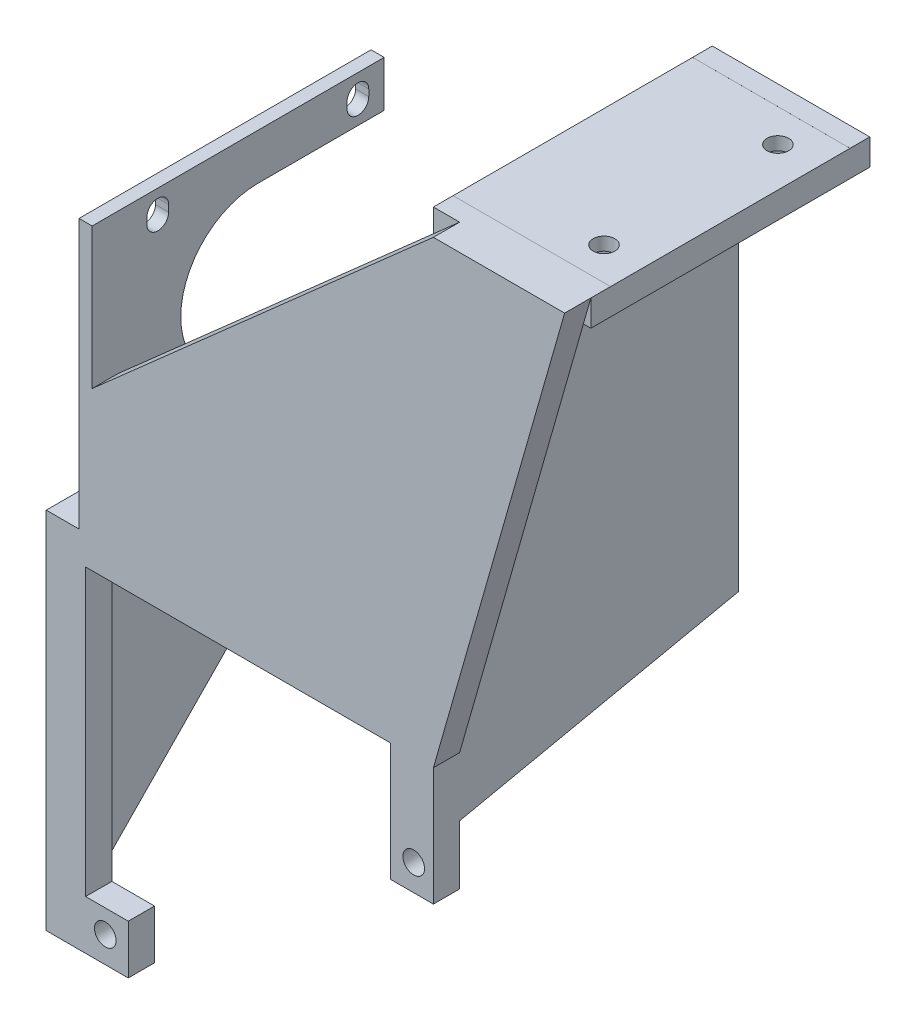
from build123d import *

# Parameters (mm, degrees)
SKETCH1_W                 = 13
SKETCH1_H                 = 16
BOSS_EXTRUDE1_DEPTH       = 4
SKETCH2_R                 = 1.65
CUT_EXTRUDE1_DEPTH        = 10
SKETCH3_W                 = 4
SKETCH3_H                 = 13
BOSS_EXTRUDE2_DEPTH       = 4
SKETCH4_W                 = 13
SKETCH4_H                 = 4
BOSS_EXTRUDE3_DEPTH       = 60
SKETCH6_W                 = 4
SKETCH6_H                 = 21
SKETCH6_H_2               = 13
BOSS_EXTRUDE4_DEPTH       = 28
SKETCH12_W                = 4
SKETCH12_H                = 28
BOSS_EXTRUDE8_DEPTH       = 1.65
SKETCH13_W                = 4
SKETCH13_H                = 28
BOSS_EXTRUDE9_DEPTH       = 1.65
SKETCH14_W                = 4
SKETCH14_H                = 35.878399396
CUT_EXTRUDE5_DEPTH        = 24
SKETCH15_R                = 1.65
CUT_EXTRUDE6_DEPTH        = 24
SKETCH16_W                = 4
SKETCH16_H                = 11.121600604
SKETCH16_H_2              = 11.3
BOSS_EXTRUDE10_DEPTH      = 29.15
SKETCH17_R                = 1.65
CUT_EXTRUDE8_DEPTH        = 29.15
SKETCH18_W                = 22.65
SKETCH18_H                = 4
SKETCH18_W_2              = 13
BOSS_EXTRUDE11_DEPTH      = 4
SKETCH19_W                = 4
SKETCH19_H                = 20
BOSS_EXTRUDE12_DEPTH      = 40
SKETCH20_R                = 1.65
CUT_EXTRUDE9_DEPTH        = 40
SKETCH21_W                = 4
SKETCH21_H                = 30.5
BOSS_EXTRUDE13_DEPTH      = 38.5
SKETCH23_W                = 4
SKETCH23_H                = 4
BOSS_EXTRUDE14_DEPTH      = 38.5
SKETCH24_W                = 4
SKETCH24_H                = 38.5
BOSS_EXTRUDE15_DEPTH      = 3
SKETCH27_W                = 4
SKETCH27_H                = 58.3
CUT_EXTRUDE10_DEPTH       = 100
SKETCH29_W                = 38.5
SKETCH29_H                = 7
BOSS_EXTRUDE16_DEPTH      = 40
BOSS_EXTRUDE16_DEPTH_BACK = 28
SKETCH30_R                = 1.65
CUT_EXTRUDE11_DEPTH       = 40
SKETCH31_W                = 4
SKETCH31_H                = 22.5
CUT_EXTRUDE12_DEPTH       = 38.5
SKETCH32_W                = 38.5
SKETCH32_H                = 2.5
CUT_EXTRUDE13_DEPTH       = 40
SKETCH33_W                = 4
SKETCH33_H                = 8
BOSS_EXTRUDE17_DEPTH      = 8
SKETCH34_R                = 1.65
CUT_EXTRUDE14_DEPTH       = 8
SKETCH35_W                = 4
SKETCH35_H                = 43.5
BOSS_EXTRUDE18_DEPTH      = 13
CUT_EXTRUDE15_START       = -20
SKETCH36_W                = 10
SKETCH36_H                = 80
CUT_EXTRUDE15_DEPTH       = 20
SKETCH37_W                = 5
SKETCH37_H                = 7
BOSS_EXTRUDE19_DEPTH      = 4
SKETCH41_W                = 13
SKETCH41_H                = 20
BOSS_EXTRUDE20_DEPTH      = 4
SKETCH42_R                = 1.65
CUT_EXTRUDE18_DEPTH       = 4
SKETCH43_W                = 4
SKETCH43_H                = 38.5
CUT_EXTRUDE19_DEPTH       = 10
SKETCH44_W                = 8
SKETCH44_H                = 9
BOSS_EXTRUDE21_DEPTH      = 4
SKETCH45_R                = 1.65
CUT_EXTRUDE20_DEPTH       = 4
CUT_EXTRUDE21_DEPTH       = 3
SKETCH49_R                = 1.65
CUT_EXTRUDE22_DEPTH       = 5
SKETCH54_W                = 1
SKETCH54_H                = 38.5
CUT_EXTRUDE24_DEPTH       = 50
SKETCH55_W                = 8
SKETCH55_H                = 10
BOSS_EXTRUDE22_DEPTH      = 4
SKETCH56_R                = 1.65
CUT_EXTRUDE25_DEPTH       = 4
SKETCH57_W                = 25
SKETCH57_H                = 70
CUT_EXTRUDE26_DEPTH       = 15
CUT_EXTRUDE26_DEPTH_BACK  = 10
SKETCH58_W                = 47.5
SKETCH58_H                = 38.5
BOSS_EXTRUDE24_DEPTH      = 4.5
SKETCH59_W                = 0.5
SKETCH59_H                = 38.5
BOSS_EXTRUDE25_DEPTH      = 4.5
SKETCH60_W                = 4
SKETCH60_H                = 38.5
BOSS_EXTRUDE26_DEPTH      = 69.5
SKETCH61_W                = 38.5
SKETCH61_H                = 2.457662878
BOSS_EXTRUDE27_DEPTH      = 20
SKETCH62_W                = 38.5
SKETCH62_H                = 2
BOSS_EXTRUDE31_DEPTH      = 29.5
SKETCH64_W                = 4
SKETCH64_H                = 13
BOSS_EXTRUDE32_DEPTH      = 16
SKETCH65_R                = 1.65
CUT_EXTRUDE27_DEPTH       = 16
SKETCH66_W                = 24
SKETCH66_H                = 0.5
BOSS_EXTRUDE33_DEPTH      = 38.5
SKETCH69_W                = 20
SKETCH69_H                = 38.5
BOSS_EXTRUDE34_DEPTH      = 1.04
SKETCH70_R                = 1.65
CUT_EXTRUDE29_DEPTH       = 10
SKETCH72_W                = 2
SKETCH72_H                = 38.5
CUT_EXTRUDE31_DEPTH       = 60
SKETCH73_W                = 22.5
SKETCH73_H                = 38.5
BOSS_EXTRUDE35_DEPTH      = 2
SKETCH74_R                = 11.25
CUT_EXTRUDE32_DEPTH       = 2
SKETCH76_R                = 1.65
CUT_EXTRUDE34_DEPTH       = 5
SKETCH77_W                = 35
SKETCH77_H                = 30
CUT_EXTRUDE35_DEPTH       = 1000
SKETCH78_R                = 11.75
CUT_EXTRUDE36_DEPTH       = 10
SKETCH79_W                = 19.25
SKETCH79_H                = 23.5
CUT_EXTRUDE37_DEPTH       = 10
SKETCH80_R                = 1.65
CUT_EXTRUDE38_DEPTH       = 10
SKETCH81_W                = 3.3
SKETCH81_H                = 1
CUT_EXTRUDE39_DEPTH       = 10
CUT_EXTRUDE41_DEPTH       = 2
SKETCH83_W                = 54
SKETCH83_H                = 42.5
BOSS_EXTRUDE37_DEPTH      = 4.5
SKETCH84_W                = 2
SKETCH84_H                = 61.502337122
BOSS_EXTRUDE38_DEPTH      = 4
SKETCH85_W                = 24
SKETCH85_H                = 3
BOSS_EXTRUDE40_DEPTH      = 4
BOSS_EXTRUDE41_DEPTH      = 4
BOSS_EXTRUDE42_DEPTH      = 4
SKETCH89_W                = 6
SKETCH89_H                = 45.5
BOSS_EXTRUDE43_DEPTH      = 2
BOSS_EXTRUDE44_DEPTH      = 4
SKETCH91_R                = 1.65
CUT_EXTRUDE42_DEPTH       = 10
SKETCH92_R                = 1.65
CUT_EXTRUDE43_DEPTH       = 10
SKETCH93_W                = 3
SKETCH93_H                = 3.3
CUT_EXTRUDE44_DEPTH       = 10
SKETCH95_W                = 46.5
SKETCH95_H                = 4.5
BOSS_EXTRUDE45_DEPTH      = 5
SKETCH96_W                = 7.3
SKETCH96_H                = 4
BOSS_EXTRUDE47_DEPTH      = 18
SKETCH99_R                = 1.65
CUT_EXTRUDE47_DEPTH       = 18
SKETCH100_W               = 6
SKETCH100_H               = 4
BOSS_EXTRUDE48_DEPTH      = 51
SKETCH101_W               = 4
SKETCH101_H               = 7.5
BOSS_EXTRUDE50_DEPTH      = 6.5
SKETCH103_R               = 1.65
CUT_EXTRUDE48_DEPTH       = 6.5
SKETCH104_W               = 7.3
SKETCH104_H               = 18
CUT_EXTRUDE49_DEPTH       = 6.5
SKETCH105_W               = 6.5
SKETCH105_H               = 4
BOSS_EXTRUDE51_DEPTH      = 18
SKETCH106_R               = 1.65
CUT_EXTRUDE50_DEPTH       = 18
BOSS_EXTRUDE52_DEPTH      = 4
BOSS_EXTRUDE53_DEPTH      = 4


with BuildPart() as part:
    # Sketch1 → Boss-Extrude1 (new body)
    with BuildSketch(Plane(origin=(0, 0, 0), x_dir=(0, 0, -1), z_dir=(1, 0, 0))):
        with Locations((6.5, -8)):
            Rectangle(SKETCH1_W, SKETCH1_H)
    extrude(amount=BOSS_EXTRUDE1_DEPTH)

    # Sketch2 → Cut-Extrude1 (cut)
    with BuildSketch(Plane(origin=(4, 0, 0), x_dir=(0, 0, -1), z_dir=(1, 0, 0))):
        with Locations((6.5, -4)):
            Circle(SKETCH2_R)
        with Locations((6.5, -12)):
            Circle(SKETCH2_R)
    extrude(amount=-CUT_EXTRUDE1_DEPTH, mode=Mode.SUBTRACT)

    # Sketch3 → Boss-Extrude2 (add)
    with BuildSketch(Plane.XZ.offset(16)):
        with Locations((2, -6.5)):
            Rectangle(SKETCH3_W, SKETCH3_H)
    extrude(amount=BOSS_EXTRUDE2_DEPTH)

    # Sketch4 → Boss-Extrude3 (add)
    with BuildSketch(Plane(origin=(4, 0, 0), x_dir=(0, 0, -1), z_dir=(1, 0, 0))):
        with Locations((6.5, -18)):
            Rectangle(SKETCH4_W, SKETCH4_H)
    extrude(amount=BOSS_EXTRUDE3_DEPTH)

    # Sketch6 → Boss-Extrude4 (add)
    with BuildSketch(Plane(origin=(0, -16, 0), x_dir=(1, 0, 0), z_dir=(0, 1, 0))):
        with Locations((62, -10.5)):
            Rectangle(SKETCH6_W, SKETCH6_H)
        with Locations((62, 23.5)):
            Rectangle(SKETCH6_W, SKETCH6_H)
        with Locations((62, 6.5)):
            Rectangle(SKETCH6_W, SKETCH6_H_2)
    extrude(amount=BOSS_EXTRUDE4_DEPTH)

    # Sketch12 → Boss-Extrude8 (add)
    with BuildSketch(Plane(origin=(0, 0, -34), x_dir=(-1, 0, 0), z_dir=(0, 0, -1))):
        with Locations((-62, -2)):
            Rectangle(SKETCH12_W, SKETCH12_H)
    extrude(amount=BOSS_EXTRUDE8_DEPTH)

    # Sketch13 → Boss-Extrude9 (add)
    with BuildSketch(Plane.XY.offset(21)):
        with Locations((62, -2)):
            Rectangle(SKETCH13_W, SKETCH13_H)
    extrude(amount=BOSS_EXTRUDE9_DEPTH)

    # Sketch14 → Cut-Extrude5 (cut)
    with BuildSketch(Plane(origin=(0, 12, 0), x_dir=(1, 0, 0), z_dir=(0, 1, 0))):
        with Locations((62, 6.410800302)):
            Rectangle(SKETCH14_W, SKETCH14_H)
    extrude(amount=-CUT_EXTRUDE5_DEPTH, mode=Mode.SUBTRACT)

    # Sketch15 → Cut-Extrude6 (cut)
    with BuildSketch(Plane(origin=(64, 0, 0), x_dir=(0, 0, -1), z_dir=(1, 0, 0))):
        with Locations((-17, -11.5)):
            Circle(SKETCH15_R)
        with Locations((30, -11.5)):
            Circle(SKETCH15_R)
    extrude(amount=-CUT_EXTRUDE6_DEPTH, mode=Mode.SUBTRACT)

    # Sketch16 → Boss-Extrude10 (add)
    with BuildSketch(Plane(origin=(0, 12, 0), x_dir=(1, 0, 0), z_dir=(0, 1, 0))):
        with Locations((62, -17.089199698)):
            Rectangle(SKETCH16_W, SKETCH16_H)
        with Locations((62, 30)):
            Rectangle(SKETCH16_W, SKETCH16_H_2)
    extrude(amount=BOSS_EXTRUDE10_DEPTH)

    # Sketch17 → Cut-Extrude8 (cut)
    with BuildSketch(Plane(origin=(64, 0, 0), x_dir=(0, 0, -1), z_dir=(1, 0, 0))):
        with Locations((-17, 35.5)):
            Circle(SKETCH17_R)
        with Locations((30, 35.5)):
            Circle(SKETCH17_R)
    extrude(amount=-CUT_EXTRUDE8_DEPTH, mode=Mode.SUBTRACT)

    # Sketch18 → Boss-Extrude11 (add)
    with BuildSketch(Plane(origin=(64, 0, 0), x_dir=(0, 0, -1), z_dir=(1, 0, 0))):
        with Locations((-11.325, -18)):
            Rectangle(SKETCH18_W, SKETCH18_H)
        with Locations((24.325, -18)):
            Rectangle(SKETCH18_W, SKETCH18_H)
        with Locations((6.5, -18)):
            Rectangle(SKETCH18_W_2, SKETCH18_H)
    extrude(amount=-BOSS_EXTRUDE11_DEPTH)

    # Sketch19 → Boss-Extrude12 (add)
    with BuildSketch(Plane(origin=(0, 0, -13), x_dir=(-1, 0, 0), z_dir=(0, 0, -1))):
        with Locations((-2, -10)):
            Rectangle(SKETCH19_W, SKETCH19_H)
    extrude(amount=BOSS_EXTRUDE12_DEPTH)

    # Sketch20 → Cut-Extrude9 (cut)
    with BuildSketch(Plane.ZY):
        with Locations((-46.5, -4)):
            Circle(SKETCH20_R)
        with Locations((-46.5, -12)):
            Circle(SKETCH20_R)
    extrude(amount=-CUT_EXTRUDE9_DEPTH, mode=Mode.SUBTRACT)

    # Sketch21 → Boss-Extrude13 (add)
    with BuildSketch(Plane(origin=(0, -16, 0), x_dir=(1, 0, 0), z_dir=(0, 1, 0))):
        with Locations((26, 6.5)):
            Rectangle(SKETCH21_W, SKETCH21_H)
    extrude(amount=BOSS_EXTRUDE13_DEPTH)

    # Sketch23 → Boss-Extrude14 (add)
    with BuildSketch(Plane(origin=(0, 22.5, 0), x_dir=(1, 0, 0), z_dir=(0, 1, 0))):
        with Locations((26, 23.75)):
            Rectangle(SKETCH23_W, SKETCH23_H)
        with Locations((26, -10.75)):
            Rectangle(SKETCH23_W, SKETCH23_H)
    extrude(amount=-BOSS_EXTRUDE14_DEPTH)

    # Sketch24 → Boss-Extrude15 (add)
    with BuildSketch(Plane(origin=(0, 22.5, 0), x_dir=(1, 0, 0), z_dir=(0, 1, 0))):
        with Locations((26, 6.5)):
            Rectangle(SKETCH24_W, SKETCH24_H)
    extrude(amount=BOSS_EXTRUDE15_DEPTH)

    # Sketch27 → Cut-Extrude10 (cut)
    with BuildSketch(Plane.XZ.offset(20)):
        with Locations((62, -6.5)):
            Rectangle(SKETCH27_W, SKETCH27_H)
    extrude(amount=-CUT_EXTRUDE10_DEPTH, mode=Mode.SUBTRACT)

    # Sketch29 → Boss-Extrude16 (add, two sides)
    with BuildSketch(Plane(origin=(28, 0, 0), x_dir=(0, 0, -1), z_dir=(1, 0, 0))) as boss_extrude16_sk:
        with Locations((6.5, -16.5)):
            Rectangle(SKETCH29_W, SKETCH29_H)
    extrude(amount=BOSS_EXTRUDE16_DEPTH)
    extrude(boss_extrude16_sk.sketch, amount=-BOSS_EXTRUDE16_DEPTH_BACK)

    # Sketch30 → Cut-Extrude11 (cut)
    with BuildSketch(Plane.ZY.offset(-24)):
        with Locations((8.75, 21.5)):
            Circle(SKETCH30_R)
        with Locations((8.75, -9)):
            Circle(SKETCH30_R)
        with Locations((-21.75, 21.5)):
            Circle(SKETCH30_R)
        with Locations((-21.75, -9)):
            Circle(SKETCH30_R)
    extrude(amount=-CUT_EXTRUDE11_DEPTH, mode=Mode.SUBTRACT)

    # Sketch31 → Cut-Extrude12 (cut)
    with BuildSketch(Plane(origin=(0, 25.5, 0), x_dir=(1, 0, 0), z_dir=(0, 1, 0))):
        with Locations((26, 6.5)):
            Rectangle(SKETCH31_W, SKETCH31_H)
    extrude(amount=-CUT_EXTRUDE12_DEPTH, mode=Mode.SUBTRACT)

    # Sketch32 → Cut-Extrude13 (cut)
    with BuildSketch(Plane(origin=(68, 0, 0), x_dir=(0, 0, -1), z_dir=(1, 0, 0))):
        with Locations((6.5, -14.25)):
            Rectangle(SKETCH32_W, SKETCH32_H)
    extrude(amount=-CUT_EXTRUDE13_DEPTH, mode=Mode.SUBTRACT)

    # Sketch33 → Boss-Extrude17 (add)
    with BuildSketch(Plane(origin=(0, 25.5, 0), x_dir=(1, 0, 0), z_dir=(0, 1, 0))):
        with Locations((26, -8.75)):
            Rectangle(SKETCH33_W, SKETCH33_H)
        with Locations((26, 21.75)):
            Rectangle(SKETCH33_W, SKETCH33_H)
    extrude(amount=-BOSS_EXTRUDE17_DEPTH)

    # Sketch34 → Cut-Extrude14 (cut)
    with BuildSketch(Plane(origin=(28, 0, 0), x_dir=(0, 0, -1), z_dir=(1, 0, 0))):
        with Locations((-8.75, 21.5)):
            Circle(SKETCH34_R)
        with Locations((21.75, 21.5)):
            Circle(SKETCH34_R)
    extrude(amount=-CUT_EXTRUDE14_DEPTH, mode=Mode.SUBTRACT)

    # Sketch35 → Boss-Extrude18 (add)
    with BuildSketch(Plane(origin=(0, -13, 0), x_dir=(1, 0, 0), z_dir=(0, 1, 0))):
        with Locations((12, 9)):
            Rectangle(SKETCH35_W, SKETCH35_H)
    extrude(amount=BOSS_EXTRUDE18_DEPTH)

    # Sketch36 → Cut-Extrude15 (cut)
    with BuildSketch(Plane.XZ.offset(20).offset(CUT_EXTRUDE15_START)):
        with Locations((5, -27.25)):
            Rectangle(SKETCH36_W, SKETCH36_H)
    extrude(amount=CUT_EXTRUDE15_DEPTH, mode=Mode.SUBTRACT)

    # Sketch37 → Boss-Extrude19 (add)
    with BuildSketch(Plane.ZY.offset(-10)):
        with Locations((-28.25, -16.5)):
            Rectangle(SKETCH37_W, SKETCH37_H)
    extrude(amount=-BOSS_EXTRUDE19_DEPTH)

    # Sketch41 → Boss-Extrude20 (add)
    with BuildSketch(Plane(origin=(14, 0, 0), x_dir=(0, 0, -1), z_dir=(1, 0, 0))):
        with Locations((32.25, -10)):
            Rectangle(SKETCH41_W, SKETCH41_H)
    extrude(amount=-BOSS_EXTRUDE20_DEPTH)

    # Sketch42 → Cut-Extrude18 (cut)
    with BuildSketch(Plane.ZY.offset(-10)):
        with Locations((-32.25, -4)):
            Circle(SKETCH42_R)
        with Locations((-32.25, -12)):
            Circle(SKETCH42_R)
    extrude(amount=-CUT_EXTRUDE18_DEPTH, mode=Mode.SUBTRACT)

    # Sketch43 → Cut-Extrude19 (cut)
    with BuildSketch(Plane(origin=(0, 0, 0), x_dir=(1, 0, 0), z_dir=(0, 1, 0))):
        with Locations((12, 6.5)):
            Rectangle(SKETCH43_W, SKETCH43_H)
    extrude(amount=-CUT_EXTRUDE19_DEPTH, mode=Mode.SUBTRACT)

    # Sketch44 → Boss-Extrude21 (add)
    with BuildSketch(Plane(origin=(28, 0, 0), x_dir=(0, 0, -1), z_dir=(1, 0, 0))):
        with Locations((-8.75, -11)):
            Rectangle(SKETCH44_W, SKETCH44_H)
        with Locations((21.75, -11)):
            Rectangle(SKETCH44_W, SKETCH44_H)
    extrude(amount=-BOSS_EXTRUDE21_DEPTH)

    # Sketch45 → Cut-Extrude20 (cut)
    with BuildSketch(Plane.ZY.offset(-24)):
        with Locations((-21.75, -7)):
            Circle(SKETCH45_R)
        with Locations((8.75, -7)):
            Circle(SKETCH45_R)
    extrude(amount=-CUT_EXTRUDE20_DEPTH, mode=Mode.SUBTRACT)

    # Sketch46 → Cut-Extrude21 (cut)
    with BuildSketch(Plane(origin=(0, -15.5, 0), x_dir=(1, 0, 0), z_dir=(0, 1, 0))):
        Polygon((64, 18.285898385), (67, 20.017949192), (67, 23.482050808), (64, 25.214101615), (61, 23.482050808), (61, 20.017949192), align=None)
        Polygon((64, -12.214101615), (67, -10.482050808), (67, -7.017949192), (64, -5.285898385), (61, -7.017949192), (61, -10.482050808), align=None)
    extrude(amount=-CUT_EXTRUDE21_DEPTH, mode=Mode.SUBTRACT)

    # Sketch49 → Cut-Extrude22 (cut)
    with BuildSketch(Plane(origin=(0, -15.5, 0), x_dir=(1, 0, 0), z_dir=(0, 1, 0))):
        with Locations((64, 21.75)):
            Circle(SKETCH49_R)
        with Locations((64, -8.75)):
            Circle(SKETCH49_R)
    extrude(amount=-CUT_EXTRUDE22_DEPTH, mode=Mode.SUBTRACT)

    # Sketch54 → Cut-Extrude24 (cut)
    with BuildSketch(Plane(origin=(0, -10, 0), x_dir=(1, 0, 0), z_dir=(0, 1, 0))):
        with Locations((10.5, 6.5)):
            Rectangle(SKETCH54_W, SKETCH54_H)
    extrude(amount=-CUT_EXTRUDE24_DEPTH, mode=Mode.SUBTRACT)

    # Sketch55 → Boss-Extrude22 (add)
    with BuildSketch(Plane.ZY.offset(-24)):
        with Locations((8.75, -8)):
            Rectangle(SKETCH55_W, SKETCH55_H)
        with Locations((-21.75, -8)):
            Rectangle(SKETCH55_W, SKETCH55_H)
    extrude(amount=-BOSS_EXTRUDE22_DEPTH)

    # Sketch56 → Cut-Extrude25 (cut)
    with BuildSketch(Plane.ZY.offset(-24)):
        with Locations((-21.75, -9)):
            Circle(SKETCH56_R)
        with Locations((8.75, -9)):
            Circle(SKETCH56_R)
    extrude(amount=-CUT_EXTRUDE25_DEPTH, mode=Mode.SUBTRACT)

    # Sketch57 → Cut-Extrude26 (cut, two sides)
    with BuildSketch(Plane(origin=(0, -13, 0), x_dir=(1, 0, 0), z_dir=(0, 1, 0))) as cut_extrude26_sk:
        with Locations((11.5, 22.25)):
            Rectangle(SKETCH57_W, SKETCH57_H)
    extrude(amount=CUT_EXTRUDE26_DEPTH, mode=Mode.SUBTRACT)
    extrude(cut_extrude26_sk.sketch, amount=-CUT_EXTRUDE26_DEPTH_BACK, mode=Mode.SUBTRACT)

    # Sketch58 → Boss-Extrude24 (add)
    with BuildSketch(Plane.XZ.offset(20)):
        with Locations((51.75, -6.5)):
            Rectangle(SKETCH58_W, SKETCH58_H)
    extrude(amount=-BOSS_EXTRUDE24_DEPTH)

    # Sketch59 → Boss-Extrude25 (add)
    with BuildSketch(Plane.XZ.offset(20)):
        with Locations((75.75, -6.5)):
            Rectangle(SKETCH59_W, SKETCH59_H)
    extrude(amount=-BOSS_EXTRUDE25_DEPTH)

    # Sketch60 → Boss-Extrude26 (add)
    with BuildSketch(Plane.XZ.offset(20)):
        with Locations((78, -6.5)):
            Rectangle(SKETCH60_W, SKETCH60_H)
    extrude(amount=-BOSS_EXTRUDE26_DEPTH)

    # Sketch61 → Boss-Extrude27 (add)
    with BuildSketch(Plane(origin=(80, 0, 0), x_dir=(0, 0, -1), z_dir=(1, 0, 0))):
        with Locations((6.5, 48.271168561)):
            Rectangle(SKETCH61_W, SKETCH61_H)
    extrude(amount=BOSS_EXTRUDE27_DEPTH)

    # Sketch62 → Boss-Extrude31 (add)
    with BuildSketch(Plane.ZY.offset(-76)):
        with Locations((-6.5, 29)):
            Rectangle(SKETCH62_W, SKETCH62_H)
    extrude(amount=BOSS_EXTRUDE31_DEPTH)

    # Sketch64 → Boss-Extrude32 (add)
    with BuildSketch(Plane(origin=(0, 30, 0), x_dir=(1, 0, 0), z_dir=(0, 1, 0))):
        with Locations((48.5, 6.5)):
            Rectangle(SKETCH64_W, SKETCH64_H)
    extrude(amount=BOSS_EXTRUDE32_DEPTH)

    # Sketch65 → Cut-Extrude27 (cut)
    with BuildSketch(Plane.ZY.offset(-46.5)):
        with Locations((-6.5, 34)):
            Circle(SKETCH65_R)
        with Locations((-6.5, 42)):
            Circle(SKETCH65_R)
    extrude(amount=-CUT_EXTRUDE27_DEPTH, mode=Mode.SUBTRACT)

    # Sketch66 → Boss-Extrude33 (add)
    with BuildSketch(Plane(origin=(0, 0, -25.75), x_dir=(-1, 0, 0), z_dir=(0, 0, -1))):
        with Locations((-88, 49.75)):
            Rectangle(SKETCH66_W, SKETCH66_H)
    extrude(amount=-BOSS_EXTRUDE33_DEPTH)

    # Sketch69 → Boss-Extrude34 (add)
    with BuildSketch(Plane.XZ.offset(-47.042337122)):
        with Locations((90, -6.5)):
            Rectangle(SKETCH69_W, SKETCH69_H)
    extrude(amount=BOSS_EXTRUDE34_DEPTH)

    # Sketch70 → Cut-Extrude29 (cut)
    with BuildSketch(Plane.XZ.offset(-46.002337122)):
        with Locations((94, 6.75)):
            Circle(SKETCH70_R)
        with Locations((94, -19.75)):
            Circle(SKETCH70_R)
    extrude(amount=-CUT_EXTRUDE29_DEPTH, mode=Mode.SUBTRACT)

    # Sketch72 → Cut-Extrude31 (cut)
    with BuildSketch(Plane.XZ.offset(20)):
        with Locations((25, -6.5)):
            Rectangle(SKETCH72_W, SKETCH72_H)
    extrude(amount=-CUT_EXTRUDE31_DEPTH, mode=Mode.SUBTRACT)

    # Sketch73 → Boss-Extrude35 (add)
    with BuildSketch(Plane.ZY.offset(-26)):
        with Locations((-6.5, 6.25)):
            Rectangle(SKETCH73_W, SKETCH73_H)
    extrude(amount=-BOSS_EXTRUDE35_DEPTH)

    # Sketch74 → Cut-Extrude32 (cut)
    with BuildSketch(Plane.ZY.offset(-26)):
        with Locations((-6.5, 6.25)):
            Circle(SKETCH74_R)
    extrude(amount=-CUT_EXTRUDE32_DEPTH, mode=Mode.SUBTRACT)

    # Sketch76 → Cut-Extrude34 (cut)
    with BuildSketch(Plane.ZY.offset(-76)):
        with Locations((2.75, 36)):
            Circle(SKETCH76_R)
        with Locations((-15.75, 36)):
            Circle(SKETCH76_R)
    extrude(amount=-CUT_EXTRUDE34_DEPTH, mode=Mode.SUBTRACT)

    # Sketch77 → Cut-Extrude35 (cut)
    with BuildSketch(Plane.XY.offset(12.75)):
        with Locations((58.5, 43)):
            Rectangle(SKETCH77_W, SKETCH77_H)
    extrude(amount=-CUT_EXTRUDE35_DEPTH, mode=Mode.SUBTRACT)

    # Sketch78 → Cut-Extrude36 (cut)
    with BuildSketch(Plane.ZY.offset(-26)):
        with Locations((-6.5, 6.75)):
            Circle(SKETCH78_R)
    extrude(amount=-CUT_EXTRUDE36_DEPTH, mode=Mode.SUBTRACT)

    # Sketch79 → Cut-Extrude37 (cut)
    with BuildSketch(Plane.ZY.offset(-26)):
        with Locations((-16.125, 6.75)):
            Rectangle(SKETCH79_W, SKETCH79_H)
    extrude(amount=-CUT_EXTRUDE37_DEPTH, mode=Mode.SUBTRACT)

    # Sketch80 → Cut-Extrude38 (cut)
    with BuildSketch(Plane.ZY.offset(-26)):
        with Locations((8.75, 22.5)):
            Circle(SKETCH80_R)
        with Locations((-21.75, 22.5)):
            Circle(SKETCH80_R)
    extrude(amount=-CUT_EXTRUDE38_DEPTH, mode=Mode.SUBTRACT)

    # Sketch81 → Cut-Extrude39 (cut)
    with BuildSketch(Plane.ZY.offset(-26)):
        with Locations((8.75, 22)):
            Rectangle(SKETCH81_W, SKETCH81_H)
        with Locations((-21.75, 22)):
            Rectangle(SKETCH81_W, SKETCH81_H)
    extrude(amount=-CUT_EXTRUDE39_DEPTH, mode=Mode.SUBTRACT)

    # Sketch82 → Cut-Extrude41 (cut)
    with BuildSketch(Plane.XZ.offset(-46.002337122)):
        Polygon((97, -18.017949192), (94, -16.285898385), (91, -18.017949192), (91, -21.482050808), (94, -23.214101615), (97, -21.482050808), align=None)
        Polygon((97, 8.482050808), (94, 10.214101615), (91, 8.482050808), (91, 5.017949192), (94, 3.285898385), (97, 5.017949192), align=None)
    extrude(amount=-CUT_EXTRUDE41_DEPTH, mode=Mode.SUBTRACT)

    # Sketch83 → Boss-Extrude37 (add)
    with BuildSketch(Plane.XZ.offset(20)):
        with Locations((53, -6.5)):
            Rectangle(SKETCH83_W, SKETCH83_H)
    extrude(amount=-BOSS_EXTRUDE37_DEPTH)

    # Sketch84 → Boss-Extrude38 (add)
    with BuildSketch(Plane(origin=(80, 0, 0), x_dir=(0, 0, -1), z_dir=(1, 0, 0))):
        with Locations((26.75, 15.251168561)):
            Rectangle(SKETCH84_W, SKETCH84_H)
        with Locations((-13.75, 15.251168561)):
            Rectangle(SKETCH84_W, SKETCH84_H)
    extrude(amount=-BOSS_EXTRUDE38_DEPTH)

    # Sketch85 → Boss-Extrude40 (add)
    with BuildSketch(Plane.XZ.offset(-46.002337122)):
        with Locations((88, -26.25)):
            Rectangle(SKETCH85_W, SKETCH85_H)
        with Locations((88, 13.25)):
            Rectangle(SKETCH85_W, SKETCH85_H)
    extrude(amount=-BOSS_EXTRUDE40_DEPTH)

    # Sketch87 → Boss-Extrude41 (add)
    with BuildSketch(Plane.XY.offset(14.75)):
        Polygon((80, 50.002337122), (26, -20), (80, -20), align=None)
    extrude(amount=BOSS_EXTRUDE41_DEPTH)

    # Sketch88 → Boss-Extrude42 (add)
    with BuildSketch(Plane.XY.offset(14.75)):
        Polygon((80, -20), (100, 50.002337122), (80, 50.002337122), align=None)
    extrude(amount=BOSS_EXTRUDE42_DEPTH)

    # Sketch89 → Boss-Extrude43 (add)
    with BuildSketch(Plane.ZY.offset(-26)):
        with Locations((15.75, 2.75)):
            Rectangle(SKETCH89_W, SKETCH89_H)
    extrude(amount=-BOSS_EXTRUDE43_DEPTH)

    # Sketch90 → Boss-Extrude44 (add)
    with BuildSketch(Plane.XY.offset(18.75)):
        Polygon((28, -17.407320847), (80, 50.002337122), (28, 4.046339576), align=None)
    extrude(amount=-BOSS_EXTRUDE44_DEPTH)

    # Sketch91 → Cut-Extrude42 (cut)
    with BuildSketch(Plane.ZY.offset(-26)):
        with Locations((10.25, -9)):
            Circle(SKETCH91_R)
    extrude(amount=-CUT_EXTRUDE42_DEPTH, mode=Mode.SUBTRACT)

    # Sketch92 → Cut-Extrude43 (cut)
    with BuildSketch(Plane.ZY.offset(-26)):
        with Locations((7.25, -9)):
            Circle(SKETCH92_R)
    extrude(amount=-CUT_EXTRUDE43_DEPTH, mode=Mode.SUBTRACT)

    # Sketch93 → Cut-Extrude44 (cut)
    with BuildSketch(Plane.ZY.offset(-26)):
        with Locations((8.75, -9)):
            Rectangle(SKETCH93_W, SKETCH93_H)
    extrude(amount=-CUT_EXTRUDE44_DEPTH, mode=Mode.SUBTRACT)

    # Sketch95 → Boss-Extrude45 (add)
    with BuildSketch(Plane.ZY.offset(-26)):
        with Locations((-4.5, -17.75)):
            Rectangle(SKETCH95_W, SKETCH95_H)
    extrude(amount=BOSS_EXTRUDE45_DEPTH)

    # Sketch96 → Boss-Extrude47 (add)
    with BuildSketch(Plane.XZ.offset(20)):
        with Locations((76.35, 16.75)):
            Rectangle(SKETCH96_W, SKETCH96_H)
    extrude(amount=BOSS_EXTRUDE47_DEPTH)

    # Sketch99 → Cut-Extrude47 (cut)
    with BuildSketch(Plane.XY.offset(18.75)):
        with Locations((76.35, -34)):
            Circle(SKETCH99_R)
    extrude(amount=-CUT_EXTRUDE47_DEPTH, mode=Mode.SUBTRACT)

    # Sketch100 → Boss-Extrude48 (add)
    with BuildSketch(Plane.XZ.offset(20)):
        with Locations((24, 16.75)):
            Rectangle(SKETCH100_W, SKETCH100_H)
    extrude(amount=BOSS_EXTRUDE48_DEPTH)

    # Sketch101 → Boss-Extrude50 (add)
    with BuildSketch(Plane(origin=(27, 0, 0), x_dir=(0, 0, -1), z_dir=(1, 0, 0))):
        with Locations((-16.75, -67.25)):
            Rectangle(SKETCH101_W, SKETCH101_H)
    extrude(amount=BOSS_EXTRUDE50_DEPTH)

    # Sketch103 → Cut-Extrude48 (cut)
    with BuildSketch(Plane.XY.offset(18.75)):
        with Locations((30, -67)):
            Circle(SKETCH103_R)
    extrude(amount=-CUT_EXTRUDE48_DEPTH, mode=Mode.SUBTRACT)

    # Sketch104 → Cut-Extrude49 (cut)
    with BuildSketch(Plane.XY.offset(18.75)):
        with Locations((76.35, -29)):
            Rectangle(SKETCH104_W, SKETCH104_H)
    extrude(amount=-CUT_EXTRUDE49_DEPTH, mode=Mode.SUBTRACT)

    # Sketch105 → Boss-Extrude51 (add)
    with BuildSketch(Plane.XZ.offset(20)):
        with Locations((76.75, 16.75)):
            Rectangle(SKETCH105_W, SKETCH105_H)
    extrude(amount=BOSS_EXTRUDE51_DEPTH)

    # Sketch106 → Cut-Extrude50 (cut)
    with BuildSketch(Plane.XY.offset(18.75)):
        with Locations((77, -34)):
            Circle(SKETCH106_R)
    extrude(amount=-CUT_EXTRUDE50_DEPTH, mode=Mode.SUBTRACT)

    # Sketch107 → Boss-Extrude52 (add)
    with BuildSketch(Plane(origin=(80, 0, 0), x_dir=(0, 0, -1), z_dir=(1, 0, 0))):
        Polygon((-14.75, -29), (27.75, -20), (-14.75, -20), align=None)
    extrude(amount=-BOSS_EXTRUDE52_DEPTH)

    # Sketch110 → Boss-Extrude53 (add)
    with BuildSketch(Plane.ZY.offset(-21)):
        Polygon((-27.75, -20), (14.75, -63.5), (14.75, -20), align=None)
    extrude(amount=-BOSS_EXTRUDE53_DEPTH)


solid = part.part
